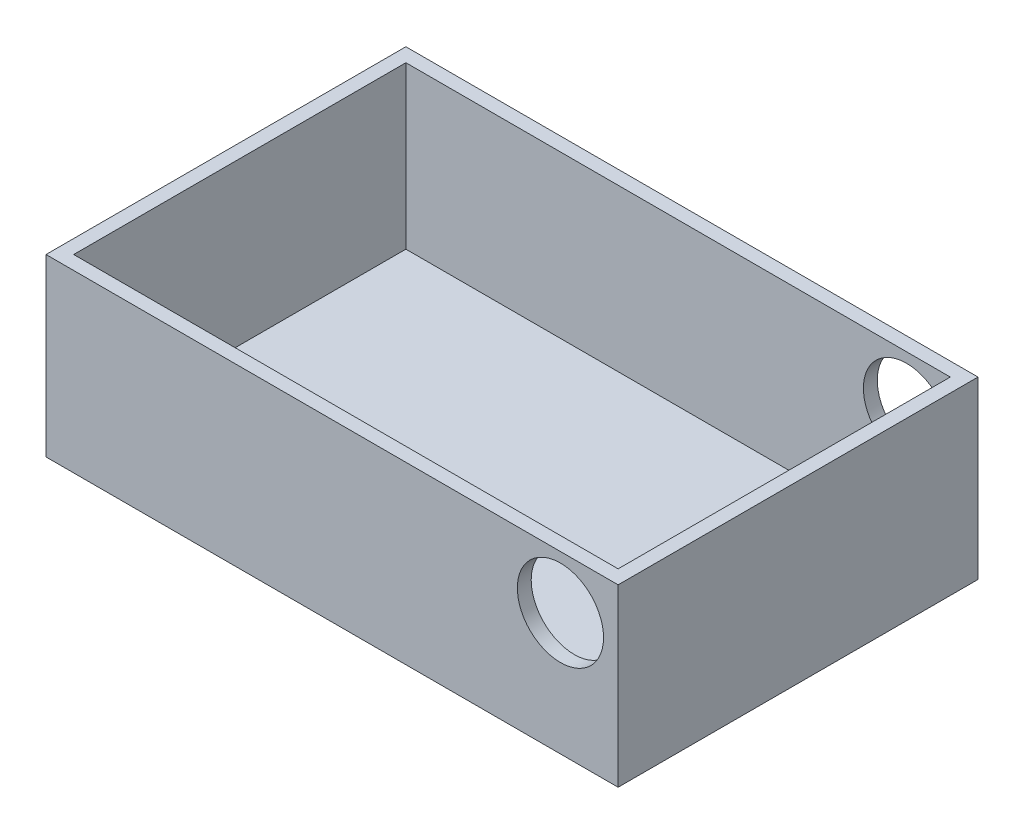
from build123d import *

# Parameters (mm, degrees)
SKETCH1_W           = 787.4
SKETCH1_H           = 495.3
BOSS_EXTRUDE1_DEPTH = 241.3
SHELL1_T            = -19.05
SKETCH2_R           = 59.309
CUT_EXTRUDE1_DEPTH  = 496.3


with BuildPart() as part:
    # Sketch1 → Boss-Extrude1 (new body)
    with BuildSketch(Plane(origin=(0, 0, 0), x_dir=(1, 0, 0), z_dir=(0, 1, 0))):
        with Locations((393.7, 247.65)):
            Rectangle(SKETCH1_W, SKETCH1_H)
    extrude(amount=BOSS_EXTRUDE1_DEPTH)

    # Shell1
    shell1_openings = [part.faces().sort_by_distance(p)[0] for p in [
        (393.7, 241.3, -247.65),
    ]]
    offset(amount=SHELL1_T, openings=shell1_openings, kind=Kind.INTERSECTION)

    # Sketch2 → Cut-Extrude1 (cut, through all)
    with BuildSketch(Plane.XY):
        with Locations((708.025, 168.275)):
            Circle(SKETCH2_R)
    extrude(amount=-CUT_EXTRUDE1_DEPTH, mode=Mode.SUBTRACT)


solid = part.part
